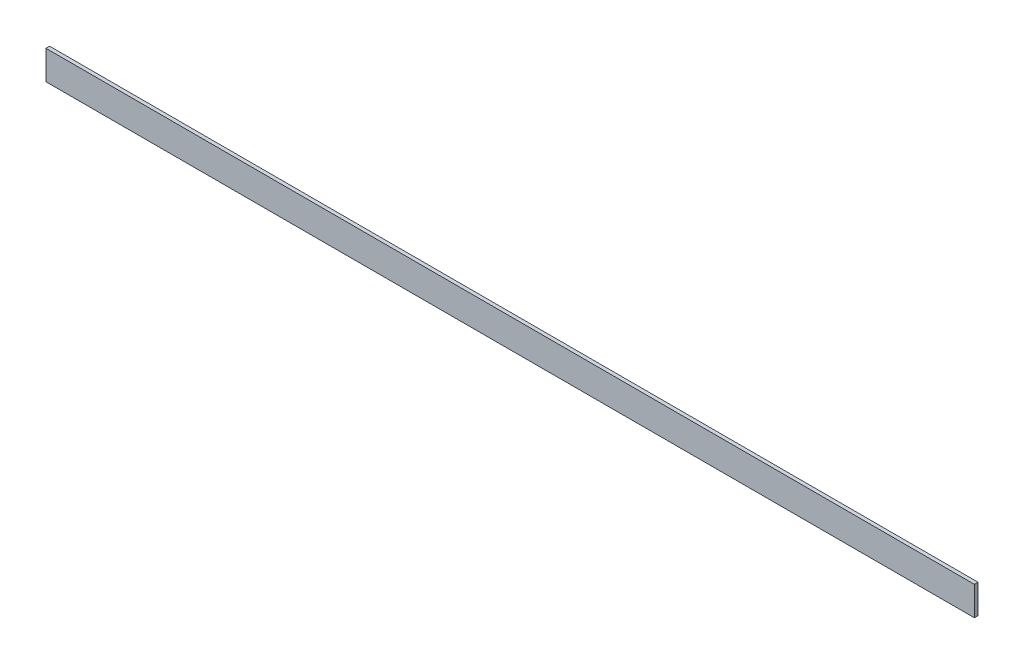
from build123d import *

# Parameters (mm, degrees)
SKETCH1_W           = 406.4
SKETCH1_H           = 1.5875
BOSS_EXTRUDE1_DEPTH = 12.7


with BuildPart() as part:
    # Sketch1 → Boss-Extrude1 (new body)
    with BuildSketch(Plane(origin=(0, 0, 0), x_dir=(1, 0, 0), z_dir=(0, 1, 0))):
        with Locations((203.2, 0.79375)):
            Rectangle(SKETCH1_W, SKETCH1_H)
    extrude(amount=BOSS_EXTRUDE1_DEPTH)


solid = part.part
